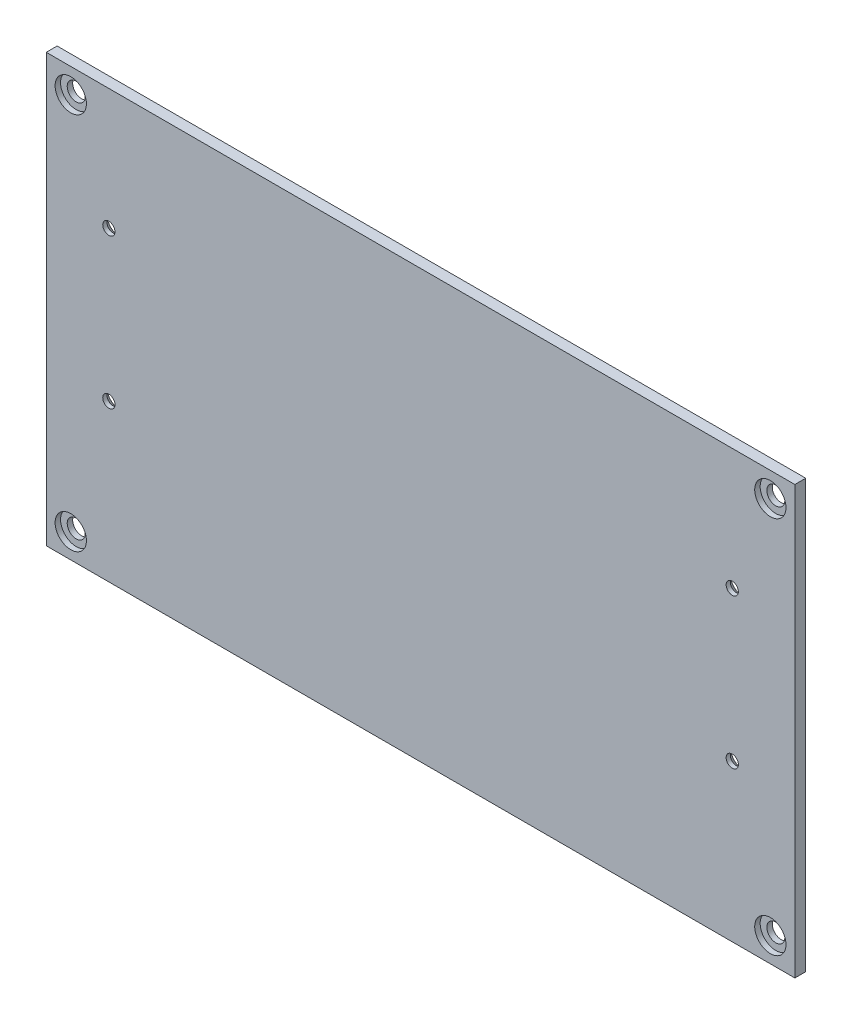
from build123d import *

# Parameters (mm, degrees)
ESQUISSE4_W                                      = 275
ESQUISSE4_H                                      = 157
BOSS_EXTRU_2_DEPTH                               = 4
FRAISAGE_POUR_VIS_T_TE_FRAIS_E_M42_AT_COUNT      = 2
FRAISAGE_POUR_VIS_T_TE_FRAIS_E_M42_AT_PITCH      = 235.512207752
FRAISAGE_POUR_VIS_T_TE_FRAIS_E_M42_2_COUNT       = 2
FRAISAGE_POUR_VIS_T_TE_FRAIS_E_M42_2_PITCH       = 229
FRAISAGE_POUR_VIS_T_TE_FRAIS_E_M42_3_COUNT       = 2
FRAISAGE_POUR_VIS_T_TE_FRAIS_E_M42_3_PITCH       = 55
CHAMBRAGE_POUR_VIS_T_TE_RONDE_6_PANS_D           = 6.6
CHAMBRAGE_POUR_VIS_T_TE_RONDE_6_PANS_CBORE_D     = 11.5
CHAMBRAGE_POUR_VIS_T_TE_RONDE_6_PANS_CBORE_DEPTH = 2


with BuildPart() as part:
    # Esquisse4 → Boss.-Extru.2 (new body)
    with BuildSketch(Plane.XY):
        Rectangle(ESQUISSE4_W, ESQUISSE4_H)
    extrude(amount=BOSS_EXTRU_2_DEPTH)

    # Esquisse6 → Fraisage pour vis à tête fraisée M42 (revolve, cut)
    with BuildSketch(Plane(origin=(-114.5, -21, 0), x_dir=(0, 1, 0), z_dir=(1, 0, 0))):
        Polygon((0, 0), (0, 4), (2.25, 4), (2.25, 2.45), (4.7, 0), align=None)
    fraisage_pour_vis_t_te_frais_e_m42 = revolve(axis=Axis((-114.5, -21, -6.35), (0, 0, 1)), mode=Mode.SUBTRACT)

    # Fraisage pour vis à tête fraisée M42 at: Fraisage pour vis à tête fraisée M42 ×2
    with Locations(*[Vector(0.972348747, 0.233533542, 0) * (i * FRAISAGE_POUR_VIS_T_TE_FRAIS_E_M42_AT_PITCH) for i in range(1, FRAISAGE_POUR_VIS_T_TE_FRAIS_E_M42_AT_COUNT)]):
        add(fraisage_pour_vis_t_te_frais_e_m42, mode=Mode.SUBTRACT)

    # Fraisage pour vis _ t_te frais_e M42 2: Fraisage pour vis à tête fraisée M42 ×2
    with Locations(*[(i * FRAISAGE_POUR_VIS_T_TE_FRAIS_E_M42_2_PITCH, 0, 0) for i in range(1, FRAISAGE_POUR_VIS_T_TE_FRAIS_E_M42_2_COUNT)]):
        add(fraisage_pour_vis_t_te_frais_e_m42, mode=Mode.SUBTRACT)

    # Fraisage pour vis _ t_te frais_e M42 3: Fraisage pour vis à tête fraisée M42 ×2
    with Locations(*[(0, i * FRAISAGE_POUR_VIS_T_TE_FRAIS_E_M42_3_PITCH, 0) for i in range(1, FRAISAGE_POUR_VIS_T_TE_FRAIS_E_M42_3_COUNT)]):
        add(fraisage_pour_vis_t_te_frais_e_m42, mode=Mode.SUBTRACT)

    # Chambrage pour Vis à tête ronde à 6 pans creux M61 (through all)
    with Locations(Plane.XY.offset(4)):
        with Locations((128.5, -69.5), (-128.5, -69.5), (-128.5, 69.5), (128.5, 69.5)):
            CounterBoreHole(CHAMBRAGE_POUR_VIS_T_TE_RONDE_6_PANS_D / 2, CHAMBRAGE_POUR_VIS_T_TE_RONDE_6_PANS_CBORE_D / 2, CHAMBRAGE_POUR_VIS_T_TE_RONDE_6_PANS_CBORE_DEPTH)


solid = part.part
